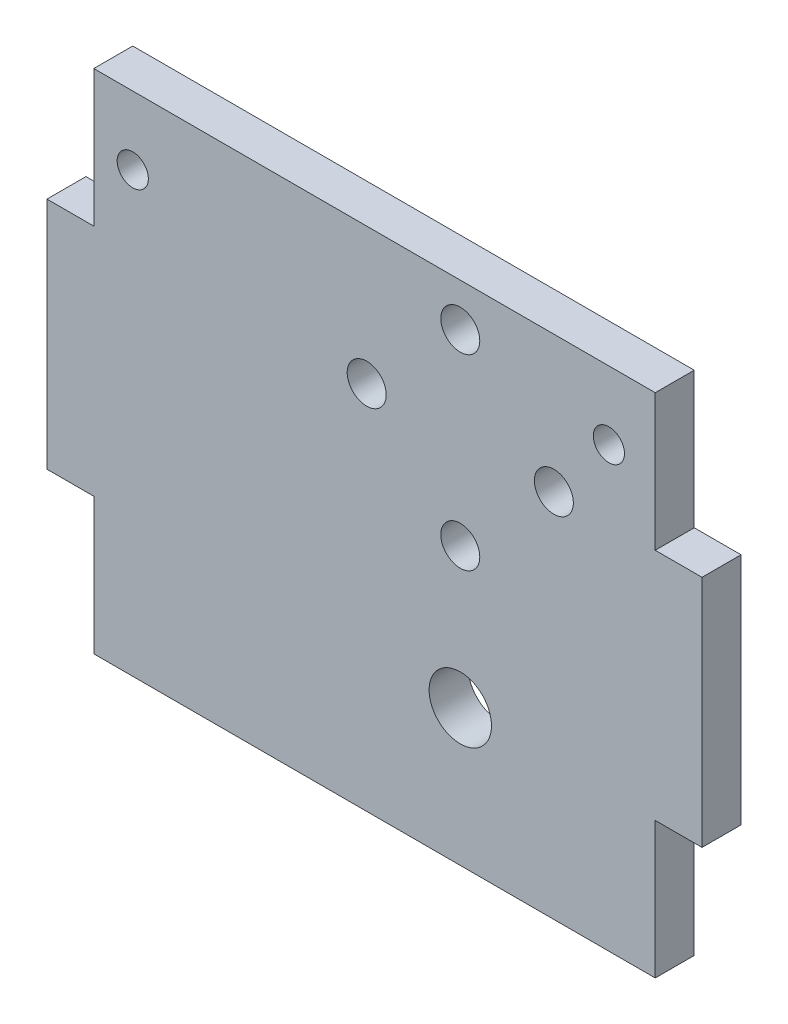
from build123d import *

# Parameters (mm, degrees)
SKETCH2_W           = 50
SKETCH2_H           = 65
SKETCH2_R           = 2
SKETCH2_R_2         = 4
BOSS_EXTRUDE1_DEPTH = 5
SKETCH4_W           = 21
SKETCH4_H           = 65
BOSS_EXTRUDE3_DEPTH = 5
SKETCH5_W           = 1
SKETCH5_H           = 65
BOSS_EXTRUDE4_DEPTH = 5
BOSS_EXTRUDE5_DEPTH = 5
SKETCH7_R           = 2
CUT_EXTRUDE1_DEPTH  = 59
SKETCH8_R           = 1.5
CUT_EXTRUDE2_DEPTH  = 10
SKETCH9_R           = 2
CUT_EXTRUDE3_DEPTH  = 10
SKETCH10_R          = 2.5
CUT_EXTRUDE4_DEPTH  = 10


with BuildPart() as part:
    # Sketch2 → Boss-Extrude1 (new body)
    with BuildSketch(Plane.XY):
        with Locations((25, 32.5)):
            Rectangle(SKETCH2_W, SKETCH2_H)
        with Locations((25, 59.5)):
            Circle(SKETCH2_R, mode=Mode.SUBTRACT)
        with Locations((13, 47.5)):
            Circle(SKETCH2_R, mode=Mode.SUBTRACT)
        with Locations((37, 47.5)):
            Circle(SKETCH2_R, mode=Mode.SUBTRACT)
        with Locations((25, 17.5)):
            Circle(SKETCH2_R_2, mode=Mode.SUBTRACT)
    extrude(amount=BOSS_EXTRUDE1_DEPTH)

    # Sketch4 → Boss-Extrude3 (add)
    with BuildSketch(Plane.XY.offset(5)):
        with Locations((-10.5, 32.5)):
            Rectangle(SKETCH4_W, SKETCH4_H)
    extrude(amount=-BOSS_EXTRUDE3_DEPTH)

    # Sketch5 → Boss-Extrude4 (add)
    with BuildSketch(Plane(origin=(0, 0, 0), x_dir=(-1, 0, 0), z_dir=(0, 0, -1))):
        with Locations((21.5, 32.5)):
            Rectangle(SKETCH5_W, SKETCH5_H)
    extrude(amount=-BOSS_EXTRUDE4_DEPTH)

    # Sketch6 → Boss-Extrude5 (add)
    with BuildSketch(Plane.XY.offset(5)):
        Polygon((-22, 17.5), (-22, 32.5), (-22, 47.5), (-28, 47.5), (-28, 17.5), align=None)
        Polygon((56, 17.5), (56, 47.5), (50, 47.5), (50, 32.5), (50, 17.5), align=None)
    extrude(amount=-BOSS_EXTRUDE5_DEPTH)

    # Sketch7 → Cut-Extrude1 (cut)
    with BuildSketch(Plane.XY.offset(5)):
        with Locations((25, 35.5)):
            Circle(SKETCH7_R)
    extrude(amount=-CUT_EXTRUDE1_DEPTH, mode=Mode.SUBTRACT)

    # Sketch8 → Cut-Extrude2 (cut)
    with BuildSketch(Plane.XY.offset(5)):
        with Locations((-17, 56.25)):
            Circle(SKETCH8_R)
        with Locations((44.055639416, 56.25)):
            Circle(SKETCH8_R)
    extrude(amount=-CUT_EXTRUDE2_DEPTH, mode=Mode.SUBTRACT)

    # Sketch9 → Cut-Extrude3 (cut)
    with BuildSketch(Plane.XY.offset(5)):
        with Locations((-17, 56.25)):
            Circle(SKETCH9_R)
        with Locations((44.055639416, 56.25)):
            Circle(SKETCH9_R)
    extrude(amount=-CUT_EXTRUDE3_DEPTH, mode=Mode.SUBTRACT)

    # Sketch10 → Cut-Extrude4 (cut)
    with BuildSketch(Plane.XY.offset(5)):
        with Locations((25, 59.5)):
            Circle(SKETCH10_R)
        with Locations((25, 35.5)):
            Circle(SKETCH10_R)
        with Locations((13, 47.5)):
            Circle(SKETCH10_R)
        with Locations((37, 47.5)):
            Circle(SKETCH10_R)
    extrude(amount=-CUT_EXTRUDE4_DEPTH, mode=Mode.SUBTRACT)


solid = part.part
